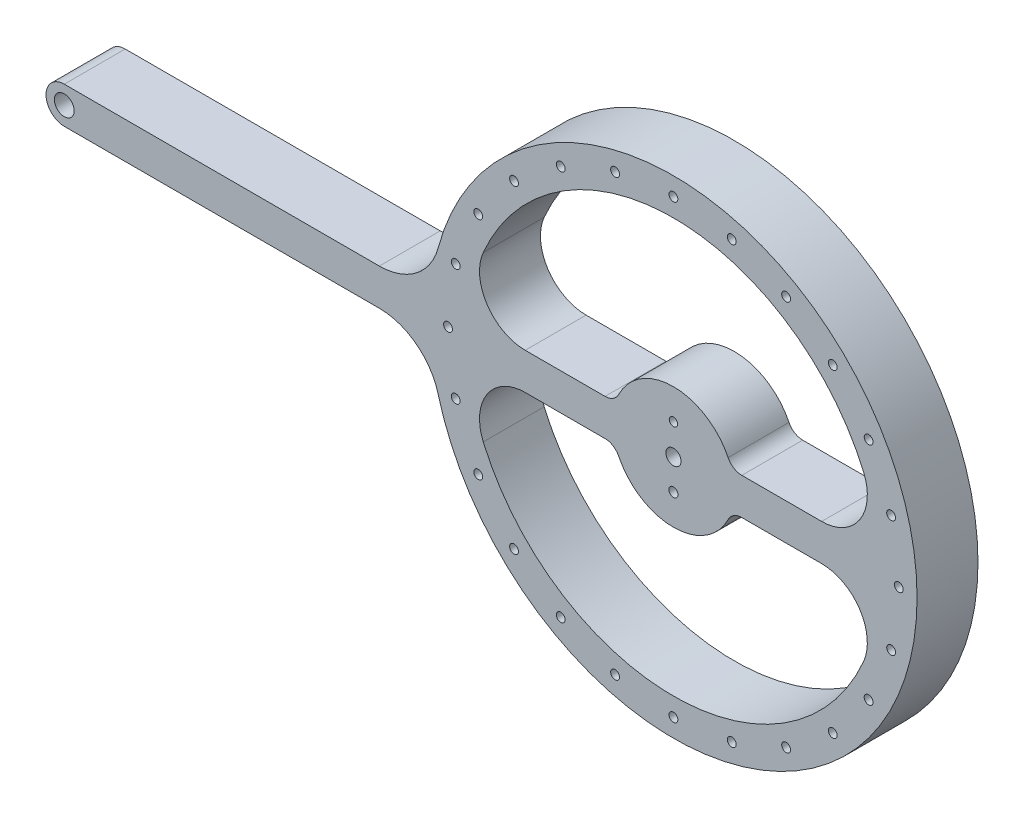
from build123d import *

# Parameters (mm, degrees)
SKETCH1_R           = 1.450000001
SKETCH1_R_2         = 3.250000001
SKETCH1_R_3         = 1.5
SKETCH1_R_4         = 2.5
SKETCH1_R_5         = 1.375000001
BOSS_EXTRUDE2_DEPTH = 20


with BuildPart() as part:
    # Sketch1 → Boss-Extrude2 (new body)
    with BuildSketch(Plane.XY):
        with BuildLine():
            Line((-155.352886895, 10.211716756), (-51.913748531, 10.211716756))
            ThreePointArc((-51.913748531, 10.211716756), (-39.74822347, 6.086224622), (-32.601576204, -4.588283244))
            ThreePointArc((-32.601576204, -4.588283244), (53.610301025, -63.284580406), (124.587919611, 13.13479368))
            ThreePointArc((124.587919611, 13.13479368), (56.661218885, 95.304455124), (-32.601576204, 37.011716756))
            ThreePointArc((-32.601576204, 37.011716756), (-39.74822347, 26.33720889), (-51.913748531, 22.211716756))
            Line((-51.913748531, 22.211716756), (-155.352886895, 22.211716756))
            ThreePointArc((-155.352886895, 22.211716756), (-161.352886895, 16.211716756), (-155.352886895, 10.211716756))
        make_face()
        with Locations((-19.438766774, -20.788283242)):
            Circle(SKETCH1_R, mode=Mode.SUBTRACT)
        with Locations((-26.831398039, -2.940892579)):
            Circle(SKETCH1_R, mode=Mode.SUBTRACT)
        with Locations((-155.352886895, 16.211716756)):
            Circle(SKETCH1_R_2, mode=Mode.SUBTRACT)
        with Locations((-26.831398039, 35.364326096)):
            Circle(SKETCH1_R, mode=Mode.SUBTRACT)
        with Locations((-19.438766774, 53.211716759)):
            Circle(SKETCH1_R, mode=Mode.SUBTRACT)
        with Locations((-29.352886893, 16.211716758)):
            Circle(SKETCH1_R, mode=Mode.SUBTRACT)
        with Locations((44.647113106, 6.211716759)):
            Circle(SKETCH1_R_3, mode=Mode.SUBTRACT)
        with Locations((116.125624253, -2.940892579)):
            Circle(SKETCH1_R, mode=Mode.SUBTRACT)
        with Locations((108.732992988, -20.788283242)):
            Circle(SKETCH1_R, mode=Mode.SUBTRACT)
        with Locations((96.973014915, -36.114185049)):
            Circle(SKETCH1_R, mode=Mode.SUBTRACT)
        with Locations((81.647113106, -47.874163121)):
            Circle(SKETCH1_R, mode=Mode.SUBTRACT)
        with Locations((63.799722443, -55.266794386)):
            Circle(SKETCH1_R, mode=Mode.SUBTRACT)
        with Locations((44.647113106, -57.788283242)):
            Circle(SKETCH1_R, mode=Mode.SUBTRACT)
        with Locations((25.494503768, -55.266794386)):
            Circle(SKETCH1_R, mode=Mode.SUBTRACT)
        with Locations((7.647113108, -47.874163121)):
            Circle(SKETCH1_R, mode=Mode.SUBTRACT)
        with Locations((-7.678788702, -36.114185049)):
            Circle(SKETCH1_R, mode=Mode.SUBTRACT)
        with Locations((44.647113106, 16.211716756)):
            Circle(SKETCH1_R_4, mode=Mode.SUBTRACT)
        with Locations((-7.678788702, 68.537618566)):
            Circle(SKETCH1_R, mode=Mode.SUBTRACT)
        with Locations((7.647113108, 80.297596638)):
            Circle(SKETCH1_R, mode=Mode.SUBTRACT)
        with Locations((25.494503768, 87.690227903)):
            Circle(SKETCH1_R, mode=Mode.SUBTRACT)
        with Locations((44.647113106, 90.211716759)):
            Circle(SKETCH1_R, mode=Mode.SUBTRACT)
        with Locations((63.799722443, 87.690227903)):
            Circle(SKETCH1_R, mode=Mode.SUBTRACT)
        with Locations((81.647113106, 80.297596638)):
            Circle(SKETCH1_R, mode=Mode.SUBTRACT)
        with Locations((96.973014915, 68.537618566)):
            Circle(SKETCH1_R, mode=Mode.SUBTRACT)
        with Locations((108.732992988, 53.211716759)):
            Circle(SKETCH1_R, mode=Mode.SUBTRACT)
        with Locations((116.125624253, 35.364326096)):
            Circle(SKETCH1_R, mode=Mode.SUBTRACT)
        with Locations((44.647113106, 26.211716758)):
            Circle(SKETCH1_R_5, mode=Mode.SUBTRACT)
        with Locations((118.647113104, 16.211716758)):
            Circle(SKETCH1_R, mode=Mode.SUBTRACT)
        with BuildLine():
            Line((-4.014987137, 10.211716754), (22.197168785, 10.211716754))
            ThreePointArc((22.197168785, 10.211716754), (24.842920096, 9.454357441), (26.687157649, 7.411716754))
            ThreePointArc((26.687157649, 7.411716754), (44.647113107, -3.788283245), (62.607068564, 7.411716755))
            ThreePointArc((62.607068564, 7.411716755), (64.451306117, 9.454357442), (67.097057428, 10.211716755))
            Line((67.097057428, 10.211716755), (93.309213348, 10.211716755))
            ThreePointArc((93.309213348, 10.211716755), (105.842188723, 3.453350593), (107.081505871, -10.731679472))
            ThreePointArc((107.081505871, -10.731679472), (44.647113106, -51.788283245), (-17.787279658, -10.731679472))
            ThreePointArc((-17.787279658, -10.731679472), (-16.54796251, 3.453350591), (-4.014987137, 10.211716754))
        make_face(mode=Mode.SUBTRACT)
        with BuildLine():
            Line((93.309213348, 22.211716754), (67.097057429, 22.211716754))
            ThreePointArc((67.097057429, 22.211716754), (64.451306116, 22.969076068), (62.607068563, 25.011716756))
            ThreePointArc((62.607068563, 25.011716756), (44.647113106, 36.211716756), (26.68715765, 25.011716756))
            ThreePointArc((26.68715765, 25.011716756), (24.842920097, 22.969076069), (22.197168786, 22.211716756))
            Line((22.197168786, 22.211716756), (-4.014987136, 22.211716756))
            ThreePointArc((-4.014987136, 22.211716756), (-16.547962509, 28.970082919), (-17.787279657, 43.155112983))
            ThreePointArc((-17.787279657, 43.155112983), (44.647113107, 84.211716756), (107.08150587, 43.155112983))
            ThreePointArc((107.08150587, 43.155112983), (105.842188723, 28.970082917), (93.309213348, 22.211716754))
        make_face(mode=Mode.SUBTRACT)
    extrude(amount=BOSS_EXTRUDE2_DEPTH)


solid = part.part
